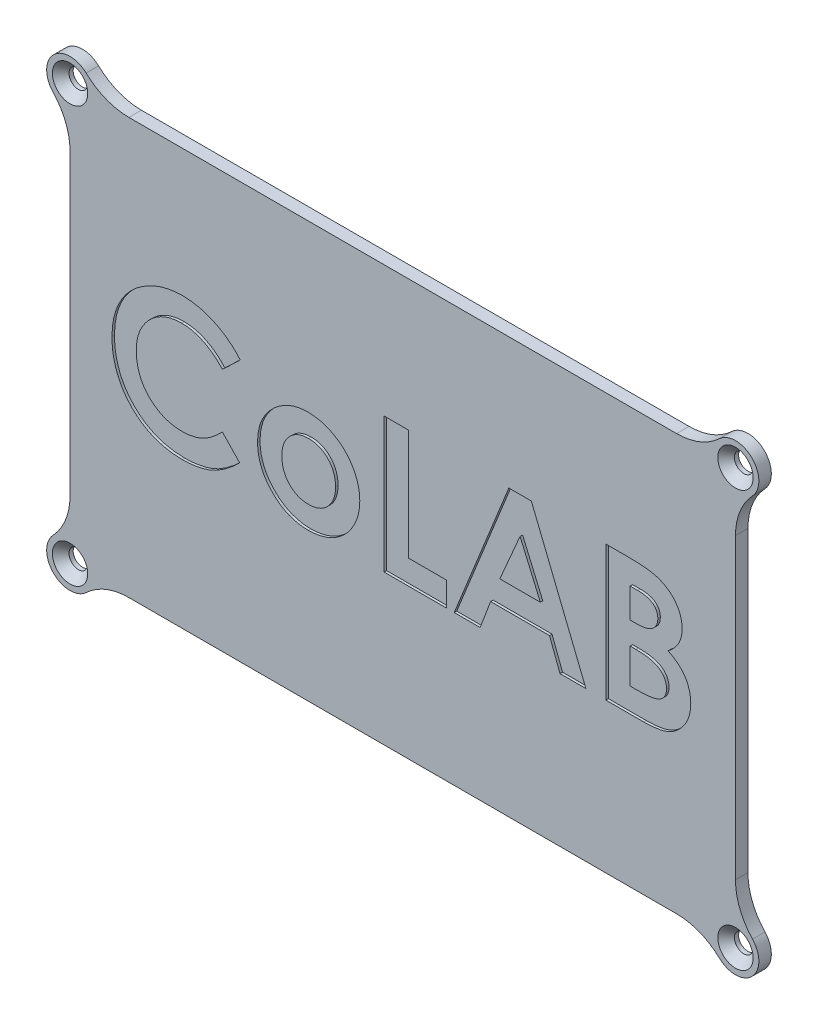
from build123d import *

# Parameters (mm, degrees)
SKETCH2_R           = 2.25
SKETCH2_W           = 146
SKETCH2_H           = 86
BOSS_EXTRUDE1_DEPTH = 3
SKETCH2_3_W         = 146
SKETCH2_3_H         = 86
BOSS_EXTRUDE2_DEPTH = 1
SKETCH3_W           = 50
SKETCH3_H           = 54
SKETCH3_W_2         = 46
SKETCH3_H_2         = 50
SKETCH3_R           = 2.875
SKETCH3_R_2         = 0.875
BOSS_EXTRUDE3_DEPTH = 2.9
CUT_EXTRUDE1_DEPTH  = 0.6
CHAMFER1_SIZE       = 2


with BuildPart() as part:
    # Sketch2 → Boss-Extrude1 (new body)
    with BuildSketch(Plane.XY):
        with BuildLine():
            ThreePointArc((76.139289209, -54.090909091), (71.383177528, -51.060194341), (65.844060434, -50))
            Line((65.844060434, -50), (-65.844060434, -50))
            ThreePointArc((-65.844060434, -50), (-71.383177528, -51.060194341), (-76.139289209, -54.090909091))
            ThreePointArc((-76.139289209, -54.090909091), (-83.977475644, -53.977475644), (-84.090909091, -46.139289209))
            ThreePointArc((-84.090909091, -46.139289209), (-81.060194341, -41.383177528), (-80, -35.844060434))
            Line((-80, -35.844060434), (-80, 35.844060434))
            ThreePointArc((-80, 35.844060434), (-81.060194341, 41.383177528), (-84.090909091, 46.139289209))
            ThreePointArc((-84.090909091, 46.139289209), (-83.977475644, 53.977475644), (-76.139289209, 54.090909091))
            ThreePointArc((-76.139289209, 54.090909091), (-71.383177528, 51.060194341), (-65.844060434, 50))
            Line((-65.844060434, 50), (65.844060434, 50))
            ThreePointArc((65.844060434, 50), (71.383177528, 51.060194341), (76.139289209, 54.090909091))
            ThreePointArc((76.139289209, 54.090909091), (83.977475644, 53.977475644), (84.090909091, 46.139289209))
            ThreePointArc((84.090909091, 46.139289209), (81.060194341, 41.383177528), (80, 35.844060434))
            Line((80, 35.844060434), (80, -35.844060434))
            ThreePointArc((80, -35.844060434), (81.060194341, -41.383177528), (84.090909091, -46.139289209))
            ThreePointArc((84.090909091, -46.139289209), (83.977475644, -53.977475644), (76.139289209, -54.090909091))
        make_face()
        with Locations((80, -50)):
            Circle(SKETCH2_R, mode=Mode.SUBTRACT)
        with Locations((-80, -50)):
            Circle(SKETCH2_R, mode=Mode.SUBTRACT)
        with Locations((-80, 50)):
            Circle(SKETCH2_R, mode=Mode.SUBTRACT)
        with Locations((80, 50)):
            Circle(SKETCH2_R, mode=Mode.SUBTRACT)
        with BuildLine():
            ThreePointArc((-74, 46), (-75.414213562, 45.414213562), (-76, 44))
            Line((-76, 44), (-76, -44))
            ThreePointArc((-76, -44), (-75.414213562, -45.414213562), (-74, -46))
            Line((-74, -46), (74, -46))
            ThreePointArc((74, -46), (75.414213562, -45.414213562), (76, -44))
            Line((76, -44), (76, 44))
            ThreePointArc((76, 44), (75.414213562, 45.414213562), (74, 46))
            Line((74, 46), (-74, 46))
        make_face(mode=Mode.SUBTRACT)
        with BuildLine():
            Line((74, 46), (-74, 46))
            ThreePointArc((-74, 46), (-75.414213562, 45.414213562), (-76, 44))
            Line((-76, 44), (-76, -44))
            ThreePointArc((-76, -44), (-75.414213562, -45.414213562), (-74, -46))
            Line((-74, -46), (74, -46))
            ThreePointArc((74, -46), (75.414213562, -45.414213562), (76, -44))
            Line((76, -44), (76, 44))
            ThreePointArc((76, 44), (75.414213562, 45.414213562), (74, 46))
        make_face()
        Rectangle(SKETCH2_W, SKETCH2_H)
    extrude(amount=BOSS_EXTRUDE1_DEPTH)

    # Sketch2_3 → Boss-Extrude2 (add)
    with BuildSketch(Plane.XY):
        with BuildLine():
            Line((76, -44), (76, 44))
            ThreePointArc((76, 44), (75.414213562, 45.414213562), (74, 46))
            Line((74, 46), (-74, 46))
            ThreePointArc((-74, 46), (-75.414213562, 45.414213562), (-76, 44))
            Line((-76, 44), (-76, -44))
            ThreePointArc((-76, -44), (-75.414213562, -45.414213562), (-74, -46))
            Line((-74, -46), (74, -46))
            ThreePointArc((74, -46), (75.414213562, -45.414213562), (76, -44))
        make_face()
        Rectangle(SKETCH2_3_W, SKETCH2_3_H, mode=Mode.SUBTRACT)
    extrude(amount=-BOSS_EXTRUDE2_DEPTH)

    # Sketch3 → Boss-Extrude3 (add)
    with BuildSketch(Plane(origin=(0, 0, 0), x_dir=(-1, 0, 0), z_dir=(0, 0, -1))):
        with Locations((-29.5, 7.5)):
            Rectangle(SKETCH3_W, SKETCH3_H)
        with Locations((-29.5, 7.5)):
            Rectangle(SKETCH3_W_2, SKETCH3_H_2, mode=Mode.SUBTRACT)
        with Locations(Location((-23.5, -11, 0), (0, 0, 180))):
            Circle(SKETCH3_R)
        with Locations(Location((-23.5, -11, 0), (0, 0, 180))):
            Circle(SKETCH3_R_2, mode=Mode.SUBTRACT)
        with Locations(Location((-35.5, 26, 0), (0, 0, 180))):
            Circle(SKETCH3_R)
        with Locations(Location((-35.5, 26, 0), (0, 0, 180))):
            Circle(SKETCH3_R_2, mode=Mode.SUBTRACT)
    extrude(amount=BOSS_EXTRUDE3_DEPTH)

    # Sketch4 → Cut-Extrude1 (cut)
    with BuildSketch(Plane.XY.offset(3)):
        with BuildLine():
            Line((-39.083333333, 12.861979167), (-43.360677083, 8.7734375))
            add(Edge.make_bspline(
                [(-43.360677083, 8.7734375), (-43.723516227, 9.148613783), (-44.432254748, 9.881450601), (-45.574299223, 10.851661967), (-46.761983894, 11.660201865), (-47.972204727, 12.34114902), (-49.226730087, 12.856334074), (-50.511054245, 13.2317581), (-51.833377987, 13.460639939), (-52.728275835, 13.486828072), (-53.178385417, 13.5)],
                knots=[0, 0, 0, 0, 1.115251505, 2.178435587, 3.19620269, 4.182487026, 5.141301733, 6.088180966, 7.038406374, 8, 8, 8, 8], degree=3))
            add(Edge.make_bspline(
                [(-53.178385417, 13.5), (-53.554281617, 13.489593717), (-54.296071352, 13.469058063), (-55.385213069, 13.318511469), (-56.42703341, 13.062500434), (-57.42509869, 12.709669804), (-58.37647206, 12.253125696), (-59.283148191, 11.693221462), (-60.142891712, 11.035013835), (-60.944345909, 10.28190841), (-61.677488042, 9.459084141), (-62.325265798, 8.581132608), (-62.867883579, 7.65006515), (-63.313201165, 6.675310933), (-63.66008635, 5.652358313), (-63.907805955, 4.581895981), (-64.051080354, 3.4626491), (-64.072465018, 2.701793411), (-64.083333333, 2.315104167)],
                knots=[0, 0, 0, 0, 1.035432265, 2.043311493, 3.022114605, 3.98653278, 4.95457646, 5.923598177, 6.917315552, 7.932509744, 8.948865224, 9.949768934, 10.933144597, 11.912367597, 12.897413939, 13.903909035, 14.934704909, 16, 16, 16, 16], degree=3))
            add(Edge.make_bspline(
                [(-64.083333333, 2.315104167), (-64.080201209, 2.043698599), (-64.074027727, 1.50875265), (-64.00644805, 0.717419122), (-63.897628836, -0.050361481), (-63.740140472, -0.793426175), (-63.543199725, -1.512418906), (-63.312143385, -2.213542389), (-63.022286606, -2.887108676), (-62.700541207, -3.540940801), (-62.326355017, -4.157198137), (-61.922913275, -4.744850652), (-61.485446575, -5.301017731), (-61.011121418, -5.823425747), (-60.493262269, -6.303910633), (-59.945253871, -6.756921139), (-59.357852079, -7.17111688), (-58.743258718, -7.556892553), (-58.096164479, -7.892019163), (-57.434126527, -8.195579127), (-56.747107033, -8.44211495), (-56.043470873, -8.640845315), (-55.325732593, -8.809835811), (-54.586872048, -8.913888452), (-53.833294232, -8.992686299), (-53.324002116, -8.997551606), (-53.067708333, -9)],
                knots=[0, 0, 0, 0, 1.103660481, 2.175337485, 3.227646561, 4.255952547, 5.262355991, 6.258840057, 7.255597736, 8.242457506, 9.22035537, 10.185017736, 11.140346927, 12.096287581, 13.051739095, 14.01125915, 14.986044842, 15.97314143, 16.960198552, 17.947847494, 18.933482797, 19.925264591, 20.920966487, 21.929612487, 22.958107872, 24, 24, 24, 24], degree=3))
            add(Edge.make_bspline(
                [(-53.067708333, -9), (-52.632990033, -8.98742564), (-51.778881617, -8.962720292), (-50.525354707, -8.76952797), (-49.330868444, -8.451737532), (-48.376479635, -8.076445491), (-47.628741212, -7.705839728), (-47.059499005, -7.363047648), (-46.470858196, -6.97959707), (-45.872595606, -6.541016153), (-45.257981968, -6.052568046), (-44.637866629, -5.503554822), (-43.996374526, -4.912054701), (-43.576139409, -4.489889443), (-43.360677083, -4.2734375)],
                knots=[0, 0, 0, 0, 1.404581149, 2.759636711, 4.088442092, 5.392261763, 6.066678138, 6.783632037, 7.538459478, 8.336747902, 9.180226004, 10.074962426, 11.012997595, 12, 12, 12, 12], degree=3))
            Line((-43.360677083, -4.2734375), (-39.213541667, -8.62890625))
            add(Edge.make_bspline(
                [(-39.213541667, -8.62890625), (-39.505062964, -8.910360911), (-40.074050193, -9.459700217), (-40.932351632, -10.239710771), (-41.789572865, -10.940636964), (-42.625005213, -11.587919346), (-43.452333928, -12.162701007), (-44.271471274, -12.66555599), (-45.073144257, -13.109202223), (-45.873999876, -13.486157833), (-46.679021465, -13.806232295), (-47.507294078, -14.081795399), (-48.361349822, -14.314911871), (-49.246404878, -14.503006249), (-50.154203994, -14.653832547), (-51.093242962, -14.755639426), (-52.057567812, -14.824080803), (-52.711684298, -14.830230828), (-53.041666667, -14.833333333)],
                knots=[0, 0, 0, 0, 1.244526981, 2.429050516, 3.560637417, 4.644440555, 5.67424972, 6.652764056, 7.595344123, 8.486817594, 9.369275933, 10.254498637, 11.166417451, 12.086725134, 13.032340136, 13.991389299, 14.986715468, 16, 16, 16, 16], degree=3))
            add(Edge.make_bspline(
                [(-53.041666667, -14.833333333), (-53.647803403, -14.817881699), (-54.833844511, -14.787647146), (-56.57195683, -14.563629578), (-58.223116876, -14.188068071), (-59.791341613, -13.656920513), (-61.276132381, -12.9784044), (-62.677109326, -12.146575506), (-63.992014385, -11.163643869), (-65.210225712, -10.041130402), (-66.312155835, -8.801408512), (-67.286134453, -7.470287308), (-68.091809603, -6.041224817), (-68.76077904, -4.535332857), (-69.283904342, -2.945739458), (-69.65209587, -1.270725163), (-69.879156899, 0.488092696), (-69.903997698, 1.689405838), (-69.916666667, 2.302083333)],
                knots=[0, 0, 0, 0, 1.078019885, 2.10938526, 3.111377082, 4.085535484, 5.04941344, 6.010039228, 6.978205633, 7.964457913, 8.951525778, 9.924444315, 10.892603023, 11.863865945, 12.85144698, 13.863884204, 14.910567087, 16, 16, 16, 16], degree=3))
            add(Edge.make_bspline(
                [(-69.916666667, 2.302083333), (-69.911313374, 2.701666369), (-69.900704458, 3.493542283), (-69.789203761, 4.660039661), (-69.633765306, 5.79716595), (-69.387176331, 6.893114011), (-69.089937642, 7.962648286), (-68.72028228, 8.994144186), (-68.278800636, 9.990566335), (-67.779722702, 10.953582802), (-67.215120828, 11.876884798), (-66.584398553, 12.752539705), (-65.903793129, 13.587307416), (-65.156950714, 14.370113188), (-64.354723909, 15.107830209), (-63.493490751, 15.796460647), (-62.578431127, 16.445880242), (-61.607068311, 17.039342037), (-60.598273295, 17.576159774), (-59.564769637, 18.049655945), (-58.509096538, 18.445389706), (-57.435717478, 18.773636263), (-56.340097445, 19.018649108), (-55.230056695, 19.204115927), (-54.096150115, 19.307793065), (-53.33483008, 19.324765674), (-52.950520833, 19.333333333)],
                knots=[0, 0, 0, 0, 1.071919942, 2.124283339, 3.142214191, 4.149696895, 5.136002878, 6.119640489, 7.086990633, 8.058538607, 9.028339693, 9.988281803, 10.952401235, 11.916291999, 12.888973767, 13.874849856, 14.873389453, 15.898127285, 16.927174885, 17.938320013, 18.946391617, 19.950418109, 20.947802303, 21.956882652, 22.968648068, 24, 24, 24, 24], degree=3))
            add(Edge.make_bspline(
                [(-52.950520833, 19.333333333), (-52.622665641, 19.328422137), (-51.970364038, 19.318650808), (-50.998977491, 19.237196146), (-50.035359638, 19.109272424), (-49.082960527, 18.91626277), (-48.134967627, 18.68713592), (-47.203838627, 18.387125915), (-46.274884462, 18.052708227), (-45.3626744, 17.652980165), (-44.465935128, 17.216640879), (-43.605674178, 16.721598113), (-42.767447846, 16.198316246), (-41.969830725, 15.615825164), (-41.19788173, 14.995252902), (-40.455637448, 14.333704141), (-39.749611507, 13.620148923), (-39.306548829, 13.11598004), (-39.083333333, 12.861979167)],
                knots=[0, 0, 0, 0, 0.996412454, 1.982464992, 2.961075852, 3.949442424, 4.934965278, 5.923860011, 6.921385422, 7.934793307, 8.949617135, 9.951082467, 10.950285876, 11.951772932, 12.951063433, 13.960125323, 14.972308753, 16, 16, 16, 16], degree=3))
        make_face()
        with BuildLine():
            add(Edge.make_bspline(
                [(-22.768229167, 10.166666667), (-22.492440428, 10.161758817), (-21.946253759, 10.152039052), (-21.132776949, 10.07113088), (-20.333521589, 9.939125862), (-19.543893666, 9.768202405), (-18.771225613, 9.528713078), (-18.011464879, 9.241482661), (-17.25781824, 8.911708552), (-16.528991053, 8.519162015), (-15.819718087, 8.093409496), (-15.147285104, 7.623769534), (-14.517276196, 7.113930992), (-13.917996254, 6.575714877), (-13.377372689, 5.985689016), (-12.860856755, 5.372283329), (-12.396354551, 4.713521632), (-11.96629242, 4.025456422), (-11.583411199, 3.312066648), (-11.250949274, 2.578314901), (-10.962403581, 1.834345819), (-10.736478086, 1.07109735), (-10.5494326, 0.298633937), (-10.431393604, -0.492510379), (-10.347476062, -1.29420856), (-10.338066246, -1.833977747), (-10.333333333, -2.10546875)],
                knots=[0, 0, 0, 0, 1.022364134, 2.024744242, 3.027414945, 4.024939316, 5.017584196, 6.023349371, 7.035562955, 8.064994934, 9.090267829, 10.101425541, 11.102933353, 12.093946398, 13.084502048, 14.067315274, 15.065326281, 16.070028806, 17.074376865, 18.064572984, 19.055292013, 20.030201733, 21.013838017, 21.999348303, 22.993720005, 24, 24, 24, 24], degree=3))
            add(Edge.make_bspline(
                [(-10.333333333, -2.10546875), (-10.338328139, -2.379080776), (-10.348258944, -2.92308351), (-10.428357571, -3.732322654), (-10.560867862, -4.527187353), (-10.73244733, -5.312360291), (-10.971040421, -6.077794433), (-11.24981098, -6.834772576), (-11.592012808, -7.572976826), (-11.970342144, -8.300460298), (-12.403169393, -8.995815371), (-12.867269518, -9.661176271), (-13.381622029, -10.279087455), (-13.917917752, -10.86871207), (-14.501594408, -11.410111648), (-15.123335426, -11.912077076), (-15.777758257, -12.380745105), (-16.46956889, -12.805119901), (-17.189906389, -13.1780029), (-17.926622393, -13.514187353), (-18.684024809, -13.794084915), (-19.460546155, -14.022333669), (-20.25665736, -14.199060966), (-21.070600819, -14.319113921), (-21.9006236, -14.402609367), (-22.459860266, -14.411950734), (-22.7421875, -14.416666667)],
                knots=[0, 0, 0, 0, 1.012026251, 2.012137606, 3.004615893, 3.992048833, 4.982446996, 5.968083444, 6.973977695, 7.990229942, 8.999482246, 10.001782172, 10.988562221, 11.971415814, 12.948383116, 13.930088534, 14.925840678, 15.924049238, 16.929462851, 17.924729459, 18.917889337, 19.913673841, 20.916777188, 21.931792057, 22.95587778, 24, 24, 24, 24], degree=3))
            add(Edge.make_bspline(
                [(-22.7421875, -14.416666667), (-23.155007487, -14.404549586), (-23.968681967, -14.380666635), (-25.167032104, -14.217074673), (-26.318251003, -13.935490015), (-27.424214562, -13.542967211), (-28.486359454, -13.039963863), (-29.495416129, -12.417420836), (-30.46142195, -11.687594219), (-31.367644968, -10.856652568), (-32.197868017, -9.945034333), (-32.923167739, -8.971887422), (-33.539005897, -7.951797671), (-34.044828423, -6.883601834), (-34.435220267, -5.765835127), (-34.717149788, -4.60183928), (-34.88094176, -3.388342471), (-34.904622717, -2.563857734), (-34.916666667, -2.14453125)],
                knots=[0, 0, 0, 0, 1.029999031, 2.030143771, 3.011211297, 3.982305373, 4.953580601, 5.938004764, 6.935448627, 7.970290061, 9.001484052, 10.007591832, 10.993831261, 11.969999897, 12.951306496, 13.942897864, 14.953773953, 16, 16, 16, 16], degree=3))
            add(Edge.make_bspline(
                [(-34.916666667, -2.14453125), (-34.904202709, -1.696782486), (-34.879705048, -0.816741255), (-34.685182846, 0.472539204), (-34.374551873, 1.706964141), (-33.928660678, 2.88308048), (-33.359073894, 4.003057407), (-32.663737516, 5.064532768), (-31.839215149, 6.067746999), (-31.20779612, 6.674525358), (-30.88671875, 6.983072917)],
                knots=[0, 0, 0, 0, 1.043912699, 2.05178951, 3.033892, 4.007821512, 4.978932272, 5.95884105, 6.962068106, 8, 8, 8, 8], degree=3))
            add(Edge.make_bspline(
                [(-30.88671875, 6.983072917), (-30.592098168, 7.238824137), (-30.010872751, 7.743368351), (-29.066572743, 8.383299971), (-28.099716091, 8.936005658), (-27.098714602, 9.39043253), (-26.060777741, 9.733063061), (-24.991224347, 9.982467432), (-23.890276817, 10.135658905), (-23.144145754, 10.15627822), (-22.768229167, 10.166666667)],
                knots=[0, 0, 0, 0, 1.048115528, 2.067714963, 3.060638214, 4.039924844, 5.017819947, 5.994373833, 6.98952318, 8, 8, 8, 8], degree=3))
        make_face()
        with BuildLine():
            add(Edge.make_bspline(
                [(-22.638020833, 4.75), (-22.863871492, 4.742493472), (-23.308460945, 4.727716791), (-23.9629083, 4.648414291), (-24.581891501, 4.485877008), (-25.177704707, 4.279174068), (-25.739807924, 4.002738008), (-26.283595158, 3.679244115), (-26.780790667, 3.274431314), (-27.255455334, 2.830381287), (-27.686345048, 2.337275648), (-28.053504002, 1.800037425), (-28.38156866, 1.239220224), (-28.630323454, 0.634291829), (-28.836191826, 0.001786689), (-28.975521072, -0.668514555), (-29.072484498, -1.369124273), (-29.079682659, -1.849046732), (-29.083333333, -2.092447917)],
                knots=[0, 0, 0, 0, 1.030650113, 2.02884584, 2.99876339, 3.944280128, 4.900564847, 5.851248946, 6.823638398, 7.81794922, 8.81432732, 9.802856497, 10.78262424, 11.771747962, 12.779760563, 13.812642396, 14.89064281, 16, 16, 16, 16], degree=3))
            add(Edge.make_bspline(
                [(-29.083333333, -2.092447917), (-29.079061547, -2.344432652), (-29.070713162, -2.836888425), (-28.984263886, -3.555940077), (-28.841706181, -4.23831533), (-28.639176359, -4.882960059), (-28.38446091, -5.494501446), (-28.071954593, -6.06950833), (-27.698359252, -6.604523418), (-27.274792812, -7.098887876), (-26.811005651, -7.547627966), (-26.302823937, -7.932719921), (-25.771528408, -8.267313718), (-25.204875133, -8.536044181), (-24.610912209, -8.743525901), (-23.987876407, -8.896287713), (-23.332493674, -8.978588372), (-22.885626225, -8.99276465), (-22.657552083, -9)],
                knots=[0, 0, 0, 0, 1.141730614, 2.231293227, 3.276944405, 4.297399982, 5.28939179, 6.275415646, 7.257752684, 8.24146775, 9.222424823, 10.176631434, 11.126518621, 12.063689483, 13.012557477, 13.974037417, 14.965980454, 16, 16, 16, 16], degree=3))
            add(Edge.make_bspline(
                [(-22.657552083, -9), (-22.429363871, -8.993582571), (-21.981982507, -8.981000685), (-21.32583015, -8.886782231), (-20.69961267, -8.738500954), (-20.100576838, -8.52923351), (-19.533565915, -8.254751016), (-18.996409333, -7.918556477), (-18.484381658, -7.52810824), (-18.014370428, -7.070901277), (-17.579290021, -6.574995073), (-17.197750527, -6.037155678), (-16.878921737, -5.462148646), (-16.617425039, -4.853591928), (-16.414498189, -4.212321979), (-16.274300554, -3.535955279), (-16.177285287, -2.82658794), (-16.17024992, -2.340183473), (-16.166666667, -2.092447917)],
                knots=[0, 0, 0, 0, 1.031504075, 2.022346795, 2.991027682, 3.937587355, 4.885570121, 5.833146507, 6.798790848, 7.791235734, 8.792807298, 9.778388351, 10.766749885, 11.760164525, 12.768777521, 13.802286646, 14.880660483, 16, 16, 16, 16], degree=3))
            add(Edge.make_bspline(
                [(-16.166666667, -2.092447917), (-16.170992795, -1.844798945), (-16.179482062, -1.358831326), (-16.265937498, -0.648504578), (-16.407096182, 0.025675916), (-16.612238193, 0.660831459), (-16.865439649, 1.264208171), (-17.178161969, 1.832717592), (-17.553599764, 2.363559666), (-17.979225279, 2.854102184), (-18.4499649, 3.296545431), (-18.949323353, 3.6910974), (-19.488719432, 4.017422192), (-20.058033741, 4.286430309), (-20.658780955, 4.493393654), (-21.290286634, 4.647021208), (-21.95448615, 4.728150764), (-22.407794685, 4.742640804), (-22.638020833, 4.75)],
                knots=[0, 0, 0, 0, 1.123894411, 2.205445421, 3.243160173, 4.246488011, 5.231014757, 6.210004299, 7.185865357, 8.177612767, 9.153374344, 10.115157457, 11.061423229, 12.009021698, 12.96873347, 13.94135618, 14.954456845, 16, 16, 16, 16], degree=3))
        make_face(mode=Mode.SUBTRACT)
        Polygon((-4.5, 18.5), (1.333333333, 18.5), (1.333333333, -8.166666667), (10.5, -8.166666667), (10.5, -14), (-4.5, -14), align=None)
        Polygon((25.506510417, 18.5), (30.916666667, 18.5), (44.041666667, -14), (37.811197917, -14), (35.28515625, -7.333333333), (21.125, -7.333333333), (18.598958333, -14), (12.375, -14), align=None)
        Polygon((28.208333333, 9.782552083), (23.338541667, -1.5), (33.078125, -1.5), align=None, mode=Mode.SUBTRACT)
        with BuildLine():
            Line((48.833333333, -14), (48.833333333, 18.5))
            Line((48.833333333, 18.5), (54.041666667, 18.5))
            add(Edge.make_bspline(
                [(54.041666667, 18.5), (54.406282566, 18.500041612), (55.111807419, 18.50012213), (56.129695657, 18.464377236), (57.073701035, 18.418137213), (57.940819361, 18.366405379), (58.73252653, 18.277261094), (59.447618624, 18.183312755), (60.087524401, 18.070016848), (60.48314337, 17.96838691), (60.669270833, 17.920572917)],
                knots=[0, 0, 0, 0, 1.311965854, 2.538629056, 3.664479157, 4.713267157, 5.663616078, 6.530575999, 7.308677837, 8, 8, 8, 8], degree=3))
            add(Edge.make_bspline(
                [(60.669270833, 17.920572917), (60.91367509, 17.853130428), (61.393274702, 17.720786614), (62.080214398, 17.453512562), (62.731872522, 17.156418504), (63.347453418, 16.81748975), (63.923177174, 16.432634479), (64.456855843, 15.998798364), (64.959999554, 15.533395568), (65.414742822, 15.023455447), (65.825755812, 14.484609249), (66.182852409, 13.916998165), (66.493123583, 13.32930134), (66.741421792, 12.714123), (66.928509827, 12.074296207), (67.065345236, 11.412553121), (67.15403311, 10.726799824), (67.162412951, 10.260259442), (67.166666667, 10.0234375)],
                knots=[0, 0, 0, 0, 1.099996261, 2.158545794, 3.195537121, 4.207578794, 5.205712374, 6.197378256, 7.190519799, 8.17788031, 9.159561366, 10.129234751, 11.085776129, 12.040971148, 13.00380137, 13.975669004, 14.972423361, 16, 16, 16, 16], degree=3))
            add(Edge.make_bspline(
                [(67.166666667, 10.0234375), (67.155544464, 9.719183467), (67.133651773, 9.120296785), (66.993799777, 8.240640601), (66.731555495, 7.409239071), (66.38841523, 6.610769779), (65.92185175, 5.84821102), (65.329406364, 5.121925371), (64.620674747, 4.409549408), (64.077038473, 3.98252807), (63.794270833, 3.760416667)],
                knots=[0, 0, 0, 0, 0.986156485, 1.941127874, 2.875419072, 3.804401753, 4.751181392, 5.761612777, 6.835722519, 8, 8, 8, 8], degree=3))
            add(Edge.make_bspline(
                [(63.794270833, 3.760416667), (64.023412163, 3.643442005), (64.472694915, 3.414087056), (65.110544432, 3.037095987), (65.701123457, 2.636118172), (66.247079969, 2.219221447), (66.736961904, 1.768732955), (67.190997311, 1.310610462), (67.586786439, 0.818605454), (67.940713005, 0.310253927), (68.248340225, -0.221805109), (68.516249611, -0.776673125), (68.742543059, -1.356245672), (68.934174204, -1.957573195), (69.077092762, -2.582723979), (69.170278702, -3.231921603), (69.241627682, -3.902951974), (69.247177962, -4.360041106), (69.25, -4.592447917)],
                knots=[0, 0, 0, 0, 1.164658916, 2.283573913, 3.35186032, 4.395461096, 5.390182219, 6.362969632, 7.312859996, 8.245001507, 9.165155236, 10.092416118, 11.032087915, 11.979892451, 12.947605196, 13.931445124, 14.948243989, 16, 16, 16, 16], degree=3))
            add(Edge.make_bspline(
                [(69.25, -4.592447917), (69.23168686, -5.036331637), (69.19554595, -5.912334379), (68.931301257, -7.198507593), (68.473184923, -8.417916455), (67.858029152, -9.565714513), (67.100038885, -10.608674897), (66.228567446, -11.522299139), (65.252388552, -12.295661778), (64.351745536, -12.817621563), (63.572760253, -13.167905389), (62.927541297, -13.384472939), (62.234589816, -13.58510079), (61.481212601, -13.72598581), (60.681067354, -13.854939272), (59.826352609, -13.934557811), (58.918665812, -13.988513333), (58.295227284, -13.996093701), (57.973958333, -14)],
                knots=[0, 0, 0, 0, 1.284142165, 2.534249414, 3.780121997, 5.041676246, 6.291546858, 7.49970053, 8.684500223, 9.883330709, 10.50184324, 11.153274765, 11.851151195, 12.587658647, 13.369265475, 14.195992086, 15.070362669, 16, 16, 16, 16], degree=3))
            Line((57.973958333, -14), (48.833333333, -14))
        make_face()
        with BuildLine():
            Line((54.666666667, 12.666666667), (54.666666667, 5.583333333))
            Line((54.666666667, 5.583333333), (56.216145833, 5.583333333))
            add(Edge.make_bspline(
                [(56.216145833, 5.583333333), (56.426733973, 5.585169742), (56.833261633, 5.588714817), (57.420447717, 5.634374152), (57.966435947, 5.712271814), (58.469155509, 5.820958648), (58.933289418, 5.958975081), (59.355872653, 6.125038573), (59.735047191, 6.327654083), (60.175560306, 6.629458826), (60.641214435, 7.073578018), (61.051124528, 7.715200209), (61.292558836, 8.453063287), (61.319448106, 8.973461463), (61.333333333, 9.2421875)],
                knots=[0, 0, 0, 0, 1.065314748, 2.056525647, 2.977365736, 3.853934255, 4.656397591, 5.425096493, 6.14721249, 6.826394842, 8.123232004, 9.372140726, 10.643011755, 12, 12, 12, 12], degree=3))
            add(Edge.make_bspline(
                [(61.333333333, 9.2421875), (61.322222609, 9.493894082), (61.300740471, 9.980558642), (61.057647165, 10.663879028), (60.680075202, 11.269440739), (60.234298431, 11.683898208), (59.814512978, 11.96696044), (59.455066913, 12.153344866), (59.060547867, 12.320194299), (58.623318371, 12.447771442), (58.145875248, 12.543500838), (57.630537704, 12.613802615), (57.076416605, 12.661652995), (56.693683983, 12.664959595), (56.49609375, 12.666666667)],
                knots=[0, 0, 0, 0, 1.347982417, 2.606269829, 3.849316587, 5.153353503, 5.842674298, 6.568177932, 7.326619318, 8.142485038, 9.012069166, 9.942760135, 10.937925643, 12, 12, 12, 12], degree=3))
            Line((56.49609375, 12.666666667), (54.666666667, 12.666666667))
        make_face(mode=Mode.SUBTRACT)
        with BuildLine():
            Line((54.666666667, 0.166666667), (54.666666667, -8.166666667))
            Line((54.666666667, -8.166666667), (56.346354167, -8.166666667))
            add(Edge.make_bspline(
                [(56.346354167, -8.166666667), (56.678430524, -8.164769527), (57.316888759, -8.161122039), (58.231479049, -8.117051708), (59.063070271, -8.037622701), (59.809459021, -7.938461985), (60.471788535, -7.804114724), (61.04781998, -7.633309399), (61.545452882, -7.445393792), (61.961703408, -7.213295705), (62.301756243, -6.943191089), (62.608618272, -6.667137682), (62.85881445, -6.348683998), (63.056774335, -6.001500368), (63.228108266, -5.634211087), (63.331444794, -5.232473638), (63.4101216, -4.808194558), (63.414451395, -4.514729893), (63.416666667, -4.364583333)],
                knots=[0, 0, 0, 0, 1.753078804, 3.370512758, 4.83203934, 6.162291463, 7.344201807, 8.395507345, 9.331626367, 10.147333109, 10.898971645, 11.62040215, 12.321813352, 13.025280112, 13.727906689, 14.453419512, 15.208716525, 16, 16, 16, 16], degree=3))
            add(Edge.make_bspline(
                [(63.416666667, -4.364583333), (63.411781358, -4.192888381), (63.40226609, -3.858472801), (63.324554782, -3.369688743), (63.183327951, -2.913376393), (63.005445867, -2.47786723), (62.757913496, -2.078753998), (62.463729733, -1.702224903), (62.108280645, -1.361030381), (61.70855741, -1.034533713), (61.242319832, -0.748668192), (60.709349164, -0.500629217), (60.106750021, -0.293476199), (59.432655787, -0.128540831), (58.69002164, 0.011437537), (57.873427166, 0.095020075), (56.989673248, 0.157184082), (56.376863898, 0.163433983), (56.059895833, 0.166666667)],
                knots=[0, 0, 0, 0, 0.845221588, 1.646264278, 2.427170338, 3.19324141, 3.95557735, 4.731569926, 5.540061037, 6.376114724, 7.268642756, 8.224665384, 9.265483498, 10.400594375, 11.639216012, 12.983232105, 14.439614077, 16, 16, 16, 16], degree=3))
            Line((56.059895833, 0.166666667), (54.666666667, 0.166666667))
        make_face(mode=Mode.SUBTRACT)
    extrude(amount=-CUT_EXTRUDE1_DEPTH, mode=Mode.SUBTRACT)

    # Chamfer1
    chamfer1_edges = [part.edges().sort_by_distance(p)[0] for p in [
        (-82.25, -50, 3),
        (-82.25, 50, 3),
        (77.75, 50, 3),
        (77.75, -50, 3),
    ]]
    chamfer(chamfer1_edges, length=CHAMFER1_SIZE)


solid = part.part
